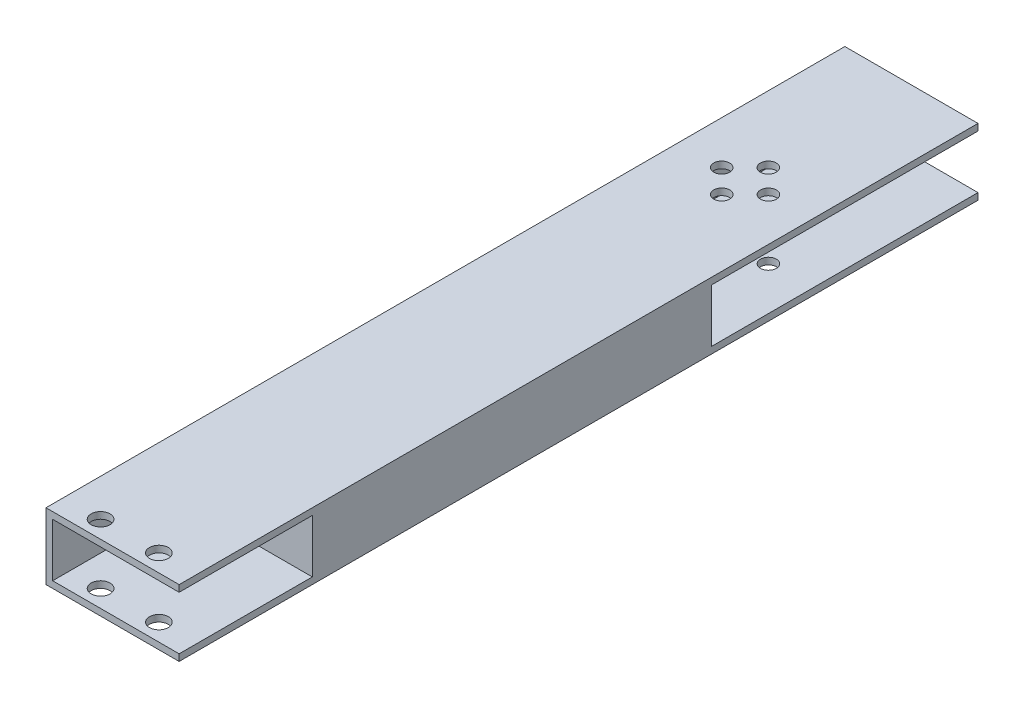
from build123d import *

# Parameters (mm, degrees)
SKETCH1_W               = 25.4
SKETCH1_H               = 12.7
BOSS_EXTRUDE1_DEPTH     = 127
SKETCH4_W               = 22.86
SKETCH4_H               = 10.16
CUT_EXTRUDE1_DEPTH      = 128
SKETCH5_R               = 1.8034
CUT_EXTRUDE2_DEPTH      = 1
CUT_EXTRUDE2_DEPTH_BACK = 13.7
SKETCH6_R               = 1.524
CUT_EXTRUDE3_DEPTH      = 1
CUT_EXTRUDE3_DEPTH_BACK = 13.7
SKETCH7_W               = 25.4
SKETCH7_H               = 12.7
SKETCH7_W_2             = 22.86
SKETCH7_H_2             = 10.16
BOSS_EXTRUDE2_DEPTH     = 25.4
CUT_EXTRUDE4_REACH      = 154.4
SKETCH8_W               = 1.27
SKETCH8_H               = 10.16
BOSS_EXTRUDE3_START     = -50.8
SKETCH9_W               = 24.13
SKETCH9_H               = 10.16
BOSS_EXTRUDE3_DEPTH     = 76.2


with BuildPart() as part:
    # Sketch1 → Boss-Extrude1 (new body)
    with BuildSketch(Plane.XY):
        Rectangle(SKETCH1_W, SKETCH1_H)
    extrude(amount=BOSS_EXTRUDE1_DEPTH)

    # Sketch4 → Cut-Extrude1 (cut, through all)
    with BuildSketch(Plane(origin=(0, 0, 0), x_dir=(-1, 0, 0), z_dir=(0, 0, -1))):
        Rectangle(SKETCH4_W, SKETCH4_H)
    extrude(amount=-CUT_EXTRUDE1_DEPTH, mode=Mode.SUBTRACT)

    # Sketch5 → Cut-Extrude2 (cut, two sides)
    with BuildSketch(Plane(origin=(0, 6.35, 0), x_dir=(1, 0, 0), z_dir=(0, 1, 0))) as cut_extrude2_sk:
        with Locations((-5.588, -123.698)):
            Circle(SKETCH5_R)
        with Locations((5.5372, -123.698)):
            Circle(SKETCH5_R)
    extrude(amount=CUT_EXTRUDE2_DEPTH, mode=Mode.SUBTRACT)
    extrude(cut_extrude2_sk.sketch, amount=-CUT_EXTRUDE2_DEPTH_BACK, mode=Mode.SUBTRACT)

    # Sketch6 → Cut-Extrude3 (cut, two sides)
    with BuildSketch(Plane(origin=(0, -6.35, 0), x_dir=(-1, 0, 0), z_dir=(0, -1, 0))) as cut_extrude3_sk:
        with Locations((4.445, -6.35)):
            Circle(SKETCH6_R)
        with Locations((-4.4704, -6.35)):
            Circle(SKETCH6_R)
        with Locations((0, -1.905)):
            Circle(SKETCH6_R)
        with Locations((0, -10.795)):
            Circle(SKETCH6_R)
    extrude(amount=CUT_EXTRUDE3_DEPTH, mode=Mode.SUBTRACT)
    extrude(cut_extrude3_sk.sketch, amount=-CUT_EXTRUDE3_DEPTH_BACK, mode=Mode.SUBTRACT)

    # Sketch7 → Boss-Extrude2 (add)
    with BuildSketch(Plane(origin=(0, 0, 0), x_dir=(-1, 0, 0), z_dir=(0, 0, -1))):
        Rectangle(SKETCH7_W, SKETCH7_H)
        Rectangle(SKETCH7_W_2, SKETCH7_H_2, mode=Mode.SUBTRACT)
    extrude(amount=BOSS_EXTRUDE2_DEPTH)

    # Sketch8 → Cut-Extrude4 (cut, up to next)
    with BuildSketch(Plane(origin=(0, 0, -25.4), x_dir=(-1, 0, 0), z_dir=(0, 0, -1)), mode=Mode.PRIVATE) as cut_extrude4_sk1:
        with Locations((-12.065, 0)):
            Rectangle(SKETCH8_W, SKETCH8_H)
    cut_extrude4_tool1 = extrude(cut_extrude4_sk1.sketch, amount=-CUT_EXTRUDE4_REACH, mode=Mode.PRIVATE) & part.part
    add(cut_extrude4_tool1.solids().sort_by_distance((12.065, 0, -25.4))[0], mode=Mode.SUBTRACT)

    # Sketch9 → Boss-Extrude3 (add)
    with BuildSketch(Plane(origin=(0, 0, -25.4), x_dir=(-1, 0, 0), z_dir=(0, 0, -1)).offset(BOSS_EXTRUDE3_START)):
        with Locations((-0.635, 0)):
            Rectangle(SKETCH9_W, SKETCH9_H)
    extrude(amount=-BOSS_EXTRUDE3_DEPTH)


solid = part.part
